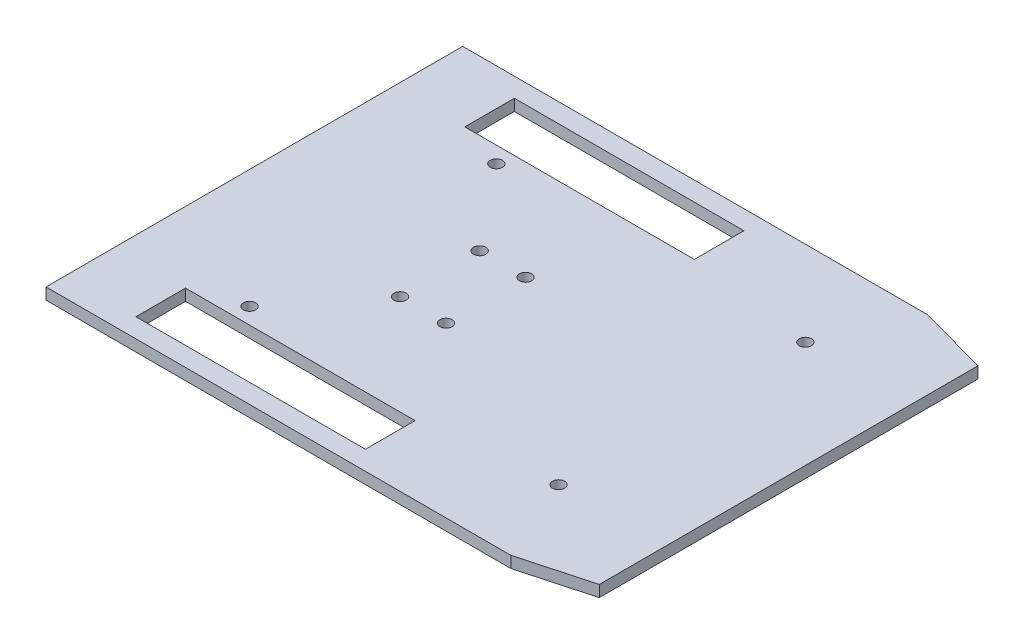
from build123d import *

# Parameters (mm, degrees)
SKETCH1_W           = 110
SKETCH1_H           = 90
BOSS_EXTRUDE1_DEPTH = 3
SKETCH2_W           = 60
SKETCH2_H           = 8.5
SKETCH2_R           = 1.6
CUT_EXTRUDE1_DEPTH  = 3
SKETCH4_R           = 1.6
CUT_EXTRUDE2_DEPTH  = 10
BOSS_EXTRU_1_DEPTH  = 3


with BuildPart() as part:
    # Sketch1 → Boss-Extrude1 (new body)
    with BuildSketch(Plane(origin=(0, 0, 0), x_dir=(1, 0, 0), z_dir=(0, 1, 0))):
        with Locations((55, 45)):
            Rectangle(SKETCH1_W, SKETCH1_H)
    extrude(amount=BOSS_EXTRUDE1_DEPTH)

    # Sketch2 → Cut-Extrude1 (cut)
    with BuildSketch(Plane(origin=(0, 3, 0), x_dir=(1, 0, 0), z_dir=(0, 1, 0))):
        with Locations((40, 85.75)):
            Rectangle(SKETCH2_W, SKETCH2_H)
        with Locations((40, 4.25)):
            Rectangle(SKETCH2_W, SKETCH2_H)
        with Locations(Location((40, 55.4, 0), (0, 0, 270))):
            Circle(SKETCH2_R)
        with Locations(Location((52, 55.4, 0), (0, 0, 270))):
            Circle(SKETCH2_R)
        with Locations(Location((52, 34.6, 0), (0, 0, 270))):
            Circle(SKETCH2_R)
        with Locations(Location((40, 34.6, 0), (0, 0, 270))):
            Circle(SKETCH2_R)
    extrude(amount=-CUT_EXTRUDE1_DEPTH, mode=Mode.SUBTRACT)

    # Sketch4 → Cut-Extrude2 (cut)
    with BuildSketch(Plane(origin=(0, 3, 0), x_dir=(1, 0, 0), z_dir=(0, 1, 0))):
        with Locations(Location((22.5, 77.26, 0), (0, 0, 270))):
            Circle(SKETCH4_R)
        with Locations(Location((22.5, 12.74, 0), (0, 0, 270))):
            Circle(SKETCH4_R)
        with Locations(Location((103.27, 12.74, 0), (0, 0, 270))):
            Circle(SKETCH4_R)
        with Locations(Location((103.27, 77.26, 0), (0, 0, 270))):
            Circle(SKETCH4_R)
    extrude(amount=-CUT_EXTRUDE2_DEPTH, mode=Mode.SUBTRACT)

    # Esquisse1 → Boss.-Extru.1 (add)
    with BuildSketch(Plane(origin=(0, 3, 0), x_dir=(1, 0, 0), z_dir=(0, 1, 0))):
        Polygon((113, -9.466090987), (-8.5, -9.466090987), (-8.5, -4.466090987), (-8.5, 94.466090987), (-8.5, 99.466090987), (113, 99.466090987), (131.165303172, 94.5), (131.165303172, -4.5), align=None)
        Polygon((10, 0), (10, -4.466090987), (70, -4.466090987), (70, 0), (110, 0), (110, 90), (70, 90), (70, 94.466090987), (10, 94.466090987), (10, 90), (0, 90), (0, 0), align=None, mode=Mode.SUBTRACT)
    extrude(amount=-BOSS_EXTRU_1_DEPTH)


solid = part.part
